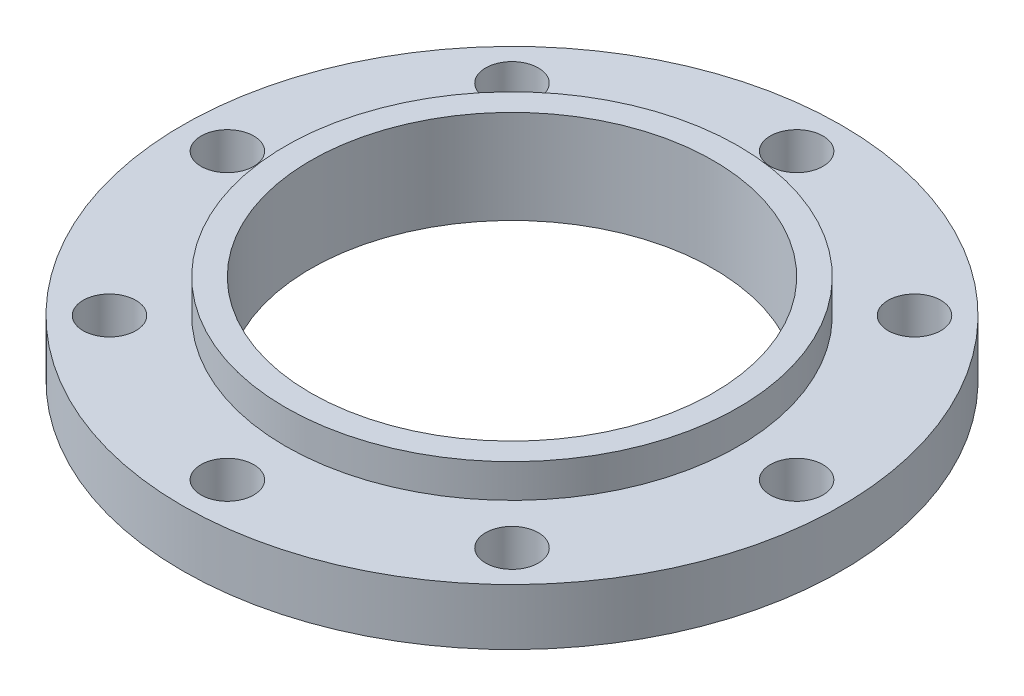
from build123d import *

# Parameters (mm, degrees)
SKETCH1_R               = 5.5
BOSS_EXTRUDE1_DEPTH     = 0.94
SKETCH3_R               = 3.78
BOSS_EXTRUDE2_DEPTH     = 1.5
SKETCH4_R               = 4.25
BOSS_EXTRUDE3_DEPTH     = 0.0625
SKETCH5_R               = 3.36
CUT_EXTRUDE1_DEPTH      = 20
CUT_EXTRUDE1_DEPTH_BACK = 6.0625
SKETCH7_R               = 0.44
CUT_EXTRUDE2_DEPTH      = 7.0625
CIRPATTERN1_COUNT       = 8
SCALE1_SCALE            = 25.4


with BuildPart() as part:
    # Sketch1 → Boss-Extrude1 (new body)
    with BuildSketch(Plane(origin=(0, 0, 0), x_dir=(1, 0, 0), z_dir=(0, 1, 0))):
        Circle(SKETCH1_R)
    extrude(amount=BOSS_EXTRUDE1_DEPTH)

    # Sketch3 → Boss-Extrude2 (add)
    with BuildSketch(Plane(origin=(0, 0, 0), x_dir=(1, 0, 0), z_dir=(0, 1, 0))):
        Circle(SKETCH3_R)
    extrude(amount=BOSS_EXTRUDE2_DEPTH)

    # Sketch4 → Boss-Extrude3 (add)
    with BuildSketch(Plane(origin=(0, 0, 0), x_dir=(1, 0, 0), z_dir=(0, 1, 0))):
        Circle(SKETCH4_R)
    extrude(amount=-BOSS_EXTRUDE3_DEPTH)

    # Sketch5 → Cut-Extrude1 (cut, two sides)
    with BuildSketch(Plane(origin=(0, 0, 0), x_dir=(1, 0, 0), z_dir=(0, 1, 0))) as cut_extrude1_sk:
        Circle(SKETCH5_R)
    extrude(amount=CUT_EXTRUDE1_DEPTH, mode=Mode.SUBTRACT)
    extrude(cut_extrude1_sk.sketch, amount=-CUT_EXTRUDE1_DEPTH_BACK, mode=Mode.SUBTRACT)

    # Sketch7 → Cut-Extrude2 (cut)
    with BuildSketch(Plane(origin=(0, 0, 0), x_dir=(1, 0, 0), z_dir=(0, 1, 0))):
        with Locations((0, 4.75)):
            Circle(SKETCH7_R)
    cut_extrude2 = extrude(amount=CUT_EXTRUDE2_DEPTH, mode=Mode.SUBTRACT)

    # CirPattern1: Cut-Extrude2 ×8 about axis
    cirpattern1_axis = Axis((0, 0, 0), (0, 1, 0))
    for i in range(1, CIRPATTERN1_COUNT):
        add(cut_extrude2.rotate(cirpattern1_axis, i * 360 / CIRPATTERN1_COUNT), mode=Mode.SUBTRACT)


with BuildPart() as part_1:
    # Scale1: scaled about (0, 0.526704923, 0)
    add(part.part.scale(SCALE1_SCALE).moved(Location((0, -12.851600121, 0))))


solid = part_1.part
